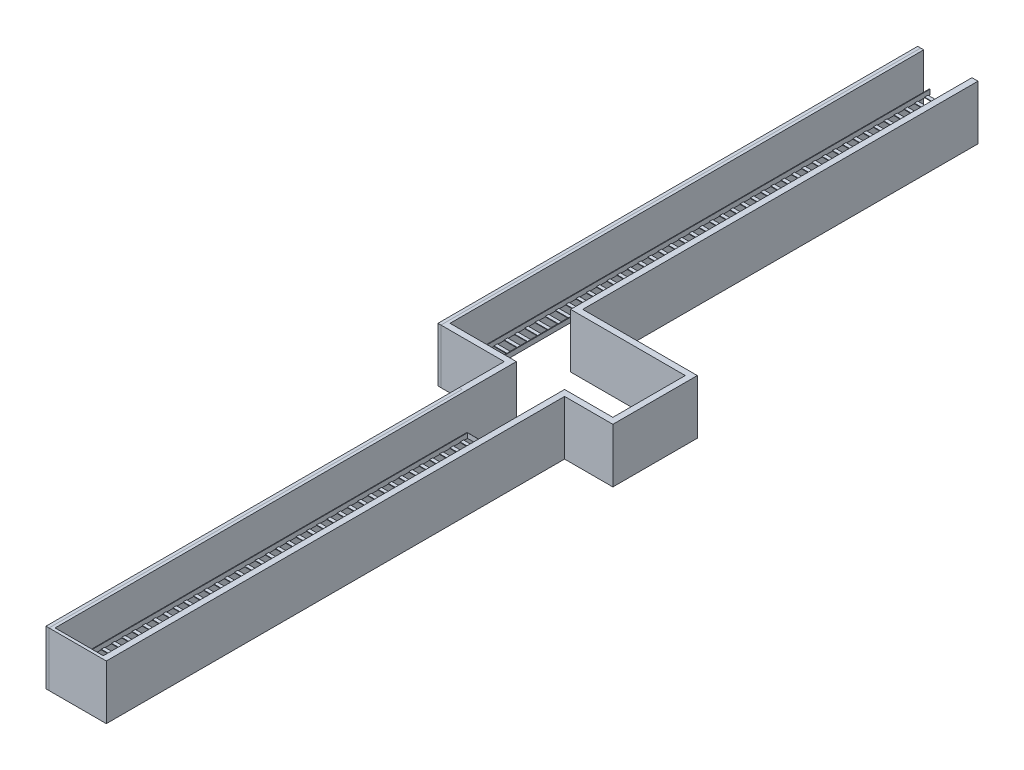
from build123d import *

# Parameters (mm, degrees)
SALIENTE_EXTRUIR1_DEPTH   = 900
CROQUIS2_W                = 700
CROQUIS2_H                = 700
CORTAR_EXTRUIR1_DEPTH     = 900
CROQUIS4_W                = 304.8
CROQUIS4_H                = 80
SALIENTE_EXTRUIR2_DEPTH   = 8450
CROQUIS5_W                = 284.8
CROQUIS5_H                = 70
CORTAR_EXTRUIR2_DEPTH     = 8450
CROQUIS6_W                = 284.8
CROQUIS6_H                = 115
CORTAR_EXTRUIR3_DEPTH     = 20
MATRIZL1_COUNT            = 49
MATRIZL1_PITCH            = 170
CROQUIS7_W                = 304.8
CROQUIS7_H                = 80
SALIENTE_EXTRUIR3_DEPTH   = 6730
CROQUIS8_W                = 284.8
CROQUIS8_H                = 70
CORTAR_EXTRUIR4_DEPTH     = 6730
CROQUIS9_W                = 284.8
CROQUIS9_H                = 115
CORTAR_EXTRUIR5_DEPTH     = 10
MATRIZL2_COUNT            = 40
MATRIZL2_PITCH            = 170
SALIENTE_EXTRUIR4_DEPTH   = 2
CROQUIS18_W               = 50
CROQUIS18_H               = 8500
SALIENTE_EXTRUIR5_DEPTH   = 900
SALIENTE_EXTRUIR5_2_DEPTH = 900
SALIENTE_EXTRUIR5_3_DEPTH = 900
SALIENTE_EXTRUIR5_4_DEPTH = 900
CROQUIS76_W               = 1497
CROQUIS76_H               = 900
SALIENTE_EXTRUIR26_DEPTH  = 2200
CROQUIS78_W               = 300
CROQUIS78_H               = 900
SALIENTE_EXTRUIR27_DEPTH  = 7053
CROQUIS79_W               = 300
CROQUIS79_H               = 900
SALIENTE_EXTRUIR28_DEPTH  = 7500
CORTAR_EXTRUIR19_DEPTH    = 900
CROQUIS85_W               = 97
CROQUIS85_H               = 900
CORTAR_EXTRUIR21_DEPTH    = 800.5
CROQUIS86_W               = 97
CROQUIS86_H               = 900
SALIENTE_EXTRUIR31_DEPTH  = 800.5
CROQUIS87_W               = 100
CROQUIS87_H               = 900
SALIENTE_EXTRUIR32_DEPTH  = 797
CROQUIS88_W               = 100
CROQUIS88_H               = 900
CORTAR_EXTRUIR22_DEPTH    = 349.5
CROQUIS89_W               = 100
CROQUIS89_H               = 900
SALIENTE_EXTRUIR33_DEPTH  = 999.5
CROQUIS90_W               = 58.427012745
CROQUIS90_H               = 900
CORTAR_EXTRUIR23_DEPTH    = 500
CROQUIS91_W               = 1000
CROQUIS91_H               = 900
CORTAR_EXTRUIR24_DEPTH    = 500


with BuildPart() as part:
    # Croquis1 → Saliente-Extruir1 (new body)
    with BuildSketch(Plane(origin=(0, 0, 0), x_dir=(1, 0, 0), z_dir=(0, 1, 0))):
        Polygon((1099.5, -7450), (499.5, -7450), (499.5, -600), (-75, -600), (-600, -600), (-600, 8600), (0, 8600), (0, 0), (1099.5, 0), align=None)
        Polygon((1049.5, -50), (1049.5, -7400), (549.5, -7400), (549.5, -550), (-75, -550), (-550, -550), (-550, 8550), (-50, 8550), (-50, -50), align=None, mode=Mode.SUBTRACT)
    extrude(amount=SALIENTE_EXTRUIR1_DEPTH)

    # Croquis2 → Cortar-Extruir1 (cut)
    with BuildSketch(Plane(origin=(0, 900, 0), x_dir=(1, 0, 0), z_dir=(0, 1, 0))):
        with Locations((-250, -250)):
            Rectangle(CROQUIS2_W, CROQUIS2_H)
    extrude(amount=-CORTAR_EXTRUIR1_DEPTH, mode=Mode.SUBTRACT)


with BuildPart() as cortar_extruir1_piece_1:
    # of the separate pieces the step leaves, piece 1, a body of its own (cortar_extruir1_pieces)
    add(part.part.solids().sort_by_distance((0, 0, -8600))[0])

    # Croquis4 → Saliente-Extruir2 (add)
    with BuildSketch(Plane.XY.offset(-8550)):
        with Locations((-300, 350)):
            Rectangle(CROQUIS4_W, CROQUIS4_H)
    extrude(amount=SALIENTE_EXTRUIR2_DEPTH)

    # Croquis5 → Cortar-Extruir2 (cut)
    with BuildSketch(Plane.XY.offset(-100)):
        with Locations((-300, 355)):
            Rectangle(CROQUIS5_W, CROQUIS5_H)
    extrude(amount=-CORTAR_EXTRUIR2_DEPTH, mode=Mode.SUBTRACT)

    # Croquis6 → Cortar-Extruir3 (cut)
    with BuildSketch(Plane(origin=(0, 320, 0), x_dir=(1, 0, 0), z_dir=(0, 1, 0))):
        with Locations((-300, 8461.038901434)):
            Rectangle(CROQUIS6_W, CROQUIS6_H)
    cortar_extruir3 = extrude(amount=-CORTAR_EXTRUIR3_DEPTH, mode=Mode.SUBTRACT)

    # MatrizL1: Cortar-Extruir3 ×49
    with Locations(*[(0, 0, i * MATRIZL1_PITCH) for i in range(1, MATRIZL1_COUNT)]):
        add(cortar_extruir3, mode=Mode.SUBTRACT)


with BuildPart() as cortar_extruir1_piece_2:
    # of the separate pieces the step leaves, piece 2, a body of its own (cortar_extruir1_pieces)
    add(part.part.solids().sort_by_distance((1099.5, 0, 7450))[0])

    # Croquis7 → Saliente-Extruir3 (add)
    with BuildSketch(Plane(origin=(0, 0, 7400), x_dir=(-1, 0, 0), z_dir=(0, 0, -1))):
        with Locations((-799.5, 350)):
            Rectangle(CROQUIS7_W, CROQUIS7_H)
    extrude(amount=SALIENTE_EXTRUIR3_DEPTH)

    # Croquis8 → Cortar-Extruir4 (cut)
    with BuildSketch(Plane(origin=(0, 0, 670), x_dir=(-1, 0, 0), z_dir=(0, 0, -1))):
        with Locations((-799.5, 355)):
            Rectangle(CROQUIS8_W, CROQUIS8_H)
    extrude(amount=-CORTAR_EXTRUIR4_DEPTH, mode=Mode.SUBTRACT)

    # Croquis9 → Cortar-Extruir5 (cut)
    with BuildSketch(Plane(origin=(0, 320, 0), x_dir=(1, 0, 0), z_dir=(0, 1, 0))):
        with Locations((799.5, -7309.310824797)):
            Rectangle(CROQUIS9_W, CROQUIS9_H)
    cortar_extruir5 = extrude(amount=-CORTAR_EXTRUIR5_DEPTH, mode=Mode.SUBTRACT)

    # MatrizL2: Cortar-Extruir5 ×40
    with Locations(*[(0, 0, -i * MATRIZL2_PITCH) for i in range(1, MATRIZL2_COUNT)]):
        add(cortar_extruir5, mode=Mode.SUBTRACT)

    # Croquis12 → Saliente-Extruir4 (add)
    with BuildSketch(Plane(origin=(0, 0, 670), x_dir=(-1, 0, 0), z_dir=(0, 0, -1))):
        Polygon((-941.9, 390), (-647.1, 390), (-647.1, 310), (-951.9, 310), (-951.9, 390), align=None)
    extrude(amount=SALIENTE_EXTRUIR4_DEPTH)


with BuildPart() as body_3:
    # Croquis18 → Saliente-Extruir5 (new body)
    with BuildSketch(Plane(origin=(0, 900, 0), x_dir=(1, 0, 0), z_dir=(0, 1, 0))):
        with Locations((-625, 4350)):
            Rectangle(CROQUIS18_W, CROQUIS18_H)
    extrude(amount=-SALIENTE_EXTRUIR5_DEPTH)


with BuildPart() as body_4:
    # Croquis18 → Saliente-Extruir5 2 (new body)
    with BuildSketch(Plane(origin=(0, 900, 0), x_dir=(1, 0, 0), z_dir=(0, 1, 0))):
        with Locations((25, 4350)):
            Rectangle(CROQUIS18_W, CROQUIS18_H)
    extrude(amount=-SALIENTE_EXTRUIR5_2_DEPTH)



with BuildPart() as body_5:
    # Croquis18 → Saliente-Extruir5 3 (new body)
    with BuildSketch(Plane(origin=(0, 900, 0), x_dir=(1, 0, 0), z_dir=(0, 1, 0))):
        Polygon((100, 0), (100, 50), (1149.5, 50), (1149.5, -7450), (1099.5, -7450), (1099.5, 0), align=None)
    extrude(amount=-SALIENTE_EXTRUIR5_3_DEPTH)


with BuildPart() as body_6:
    # Croquis18 → Saliente-Extruir5 4 (new body)
    with BuildSketch(Plane(origin=(0, 900, 0), x_dir=(1, 0, 0), z_dir=(0, 1, 0))):
        Polygon((100, -600), (100, -650), (449.5, -650), (449.5, -7450), (499.5, -7450), (499.5, -600), align=None)
    extrude(amount=-SALIENTE_EXTRUIR5_4_DEPTH)


with BuildPart() as body_4_1:
    add(body_4.part)

    add(body_5.part)  # Saliente-Extruir26 merges body 5
    # Croquis76 → Saliente-Extruir26 (add)
    with BuildSketch(Plane(origin=(50, 0, 0), x_dir=(0, 0, -1), z_dir=(1, 0, 0))):
        with Locations((798.5, 450)):
            Rectangle(CROQUIS76_W, CROQUIS76_H)
    extrude(amount=SALIENTE_EXTRUIR26_DEPTH)

    # Croquis78 → Saliente-Extruir27 (add)
    with BuildSketch(Plane(origin=(0, 0, -1547), x_dir=(-1, 0, 0), z_dir=(0, 0, -1))):
        with Locations((-200, 450)):
            Rectangle(CROQUIS78_W, CROQUIS78_H)
    extrude(amount=SALIENTE_EXTRUIR27_DEPTH)

    # Croquis79 → Saliente-Extruir28 (add)
    with BuildSketch(Plane.XY.offset(-50)):
        with Locations((1299.5, 450)):
            Rectangle(CROQUIS79_W, CROQUIS79_H)
    extrude(amount=SALIENTE_EXTRUIR28_DEPTH)


with BuildPart() as cortar_extruir19_tool:
    # Croquis80 → Cortar-Extruir19 (new body)
    with BuildSketch(Plane.XZ):
        Polygon((-50, -8550), (250, -8550), (250, -1447), (2150, -1447), (2150, -150), (1349.5, -150), (1349.5, 7400), (1049.5, 7400), (1049.5, 50), (100, 50), (100, -50), (50, -50), (50, -100), (-50, -100), align=None)
    extrude(amount=-CORTAR_EXTRUIR19_DEPTH)


with BuildPart() as cortar_extruir1_piece_1_1:
    add(cortar_extruir1_piece_1.part)

    # Cortar-Extruir19: cut by cortar_extruir19_tool
    add(cortar_extruir19_tool.part, mode=Mode.SUBTRACT)



with BuildPart() as cortar_extruir1_piece_2_1:
    add(cortar_extruir1_piece_2.part)

    # Cortar-Extruir19: cut by cortar_extruir19_tool
    add(cortar_extruir19_tool.part, mode=Mode.SUBTRACT)



with BuildPart() as body_4_2:
    add(body_4_1.part)

    # Cortar-Extruir19: cut by cortar_extruir19_tool
    add(cortar_extruir19_tool.part, mode=Mode.SUBTRACT)

    # Croquis85 → Cortar-Extruir21 (cut)
    with BuildSketch(Plane(origin=(2250, 0, 0), x_dir=(0, 0, -1), z_dir=(1, 0, 0))):
        with Locations((98.5, 450)):
            Rectangle(CROQUIS85_W, CROQUIS85_H)
    extrude(amount=-CORTAR_EXTRUIR21_DEPTH, mode=Mode.SUBTRACT)

    # Croquis86 → Saliente-Extruir31 (add)
    with BuildSketch(Plane.ZY.offset(-2150)):
        with Locations((-198.5, 450)):
            Rectangle(CROQUIS86_W, CROQUIS86_H)
    extrude(amount=SALIENTE_EXTRUIR31_DEPTH)


with BuildPart() as cortar_extruir1_piece_2_2:
    add(cortar_extruir1_piece_2_1.part)

    add(body_4_2.part)  # Saliente-Extruir32 merges body 4
    # Croquis87 → Saliente-Extruir32 (add)
    with BuildSketch(Plane(origin=(0, 0, 550), x_dir=(-1, 0, 0), z_dir=(0, 0, -1))):
        with Locations((-499.5, 450)):
            Rectangle(CROQUIS87_W, CROQUIS87_H)
    extrude(amount=SALIENTE_EXTRUIR32_DEPTH)


with BuildPart() as cortar_extruir22_tool:
    # Croquis88 → Cortar-Extruir22 (new body)
    with BuildSketch(Plane.ZY.offset(-100)):
        with Locations((600, 450)):
            Rectangle(CROQUIS88_W, CROQUIS88_H)
    extrude(amount=-CORTAR_EXTRUIR22_DEPTH)


with BuildPart() as cortar_extruir1_piece_2_3:
    add(cortar_extruir1_piece_2_2.part)

    # Cortar-Extruir22: cut by cortar_extruir22_tool
    add(cortar_extruir22_tool.part, mode=Mode.SUBTRACT)


with BuildPart() as body_6_1:
    add(body_6.part)

    # Cortar-Extruir22: cut by cortar_extruir22_tool
    add(cortar_extruir22_tool.part, mode=Mode.SUBTRACT)


with BuildPart() as cortar_extruir1_piece_1_2:
    add(cortar_extruir1_piece_1_1.part)

    add(cortar_extruir1_piece_2_3.part)  # Saliente-Extruir33 merges Cortar-Extruir1 piece 2
    # Croquis89 → Saliente-Extruir33 (add)
    with BuildSketch(Plane.ZY.offset(-449.5)):
        with Locations((-197, 450)):
            Rectangle(CROQUIS89_W, CROQUIS89_H)
    extrude(amount=SALIENTE_EXTRUIR33_DEPTH)


with BuildPart() as cortar_extruir23_tool:
    # Croquis90 → Cortar-Extruir23 (new, symmetric)
    with BuildSketch(Plane(origin=(-550, 0, 0), x_dir=(0, 0, -1), z_dir=(1, 0, 0))):
        with Locations((117.786493627, 450)):
            Rectangle(CROQUIS90_W, CROQUIS90_H)
    extrude(amount=CORTAR_EXTRUIR23_DEPTH, both=True)


with BuildPart() as cortar_extruir1_piece_1_3:
    add(cortar_extruir1_piece_1_2.part)

    # Cortar-Extruir23: cut by cortar_extruir23_tool
    add(cortar_extruir23_tool.part, mode=Mode.SUBTRACT)


with BuildPart() as body_3_1:
    add(body_3.part)

    # Cortar-Extruir23: cut by cortar_extruir23_tool
    add(cortar_extruir23_tool.part, mode=Mode.SUBTRACT)


with BuildPart() as cortar_extruir24_tool:
    # Croquis91 → Cortar-Extruir24 (new body)
    with BuildSketch(Plane(origin=(0, 0, -8600), x_dir=(-1, 0, 0), z_dir=(0, 0, -1))):
        with Locations((150, 450)):
            Rectangle(CROQUIS91_W, CROQUIS91_H)
    extrude(amount=-CORTAR_EXTRUIR24_DEPTH)


with BuildPart() as cortar_extruir1_piece_1_4:
    add(cortar_extruir1_piece_1_3.part)

    # Cortar-Extruir24: cut by cortar_extruir24_tool
    add(cortar_extruir24_tool.part, mode=Mode.SUBTRACT)


with BuildPart() as body_3_2:
    add(body_3_1.part)

    # Cortar-Extruir24: cut by cortar_extruir24_tool
    add(cortar_extruir24_tool.part, mode=Mode.SUBTRACT)


solid = Compound([body_6_1.part, cortar_extruir1_piece_1_4.part, body_3_2.part])
